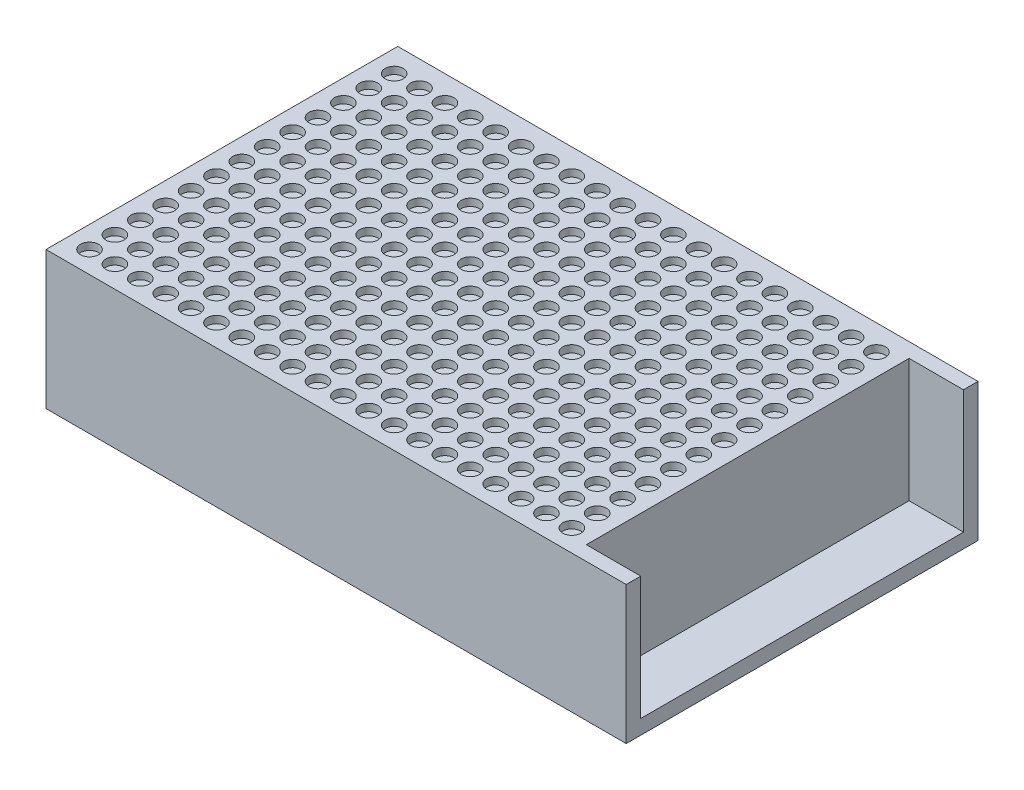
from build123d import *

# Parameters (mm, degrees)
SKETCH_1_W          = 160
SKETCH_1_H          = 97
EXTRUDE_1_DEPTH     = 38
SKETCH_2_W          = 15
SKETCH_2_H          = 89
CUT_EXTRUDE_1_DEPTH = 34
SKETCH_3_R          = 2.5
CUT_EXTRUDE_2_DEPTH = 2


with BuildPart() as part:
    # Эскиз1 → Бобышка-Вытянуть1 (new body)
    with BuildSketch(Plane(origin=(0, 0, 0), x_dir=(1, 0, 0), z_dir=(0, 1, 0))):
        with Locations((80, 48.5)):
            Rectangle(SKETCH_1_W, SKETCH_1_H)
    extrude(amount=EXTRUDE_1_DEPTH)

    # Эскиз2 → Вырез-Вытянуть1 (cut)
    with BuildSketch(Plane(origin=(0, 38, 0), x_dir=(1, 0, 0), z_dir=(0, 1, 0))):
        with Locations((152.5, 48.5)):
            Rectangle(SKETCH_2_W, SKETCH_2_H)
    extrude(amount=-CUT_EXTRUDE_1_DEPTH, mode=Mode.SUBTRACT)

    # Эскиз3 → Вырез-Вытянуть2 (cut)
    with BuildSketch(Plane(origin=(0, 38, 0), x_dir=(1, 0, 0), z_dir=(0, 1, 0))):
        with Locations((6, 6)):
            Circle(SKETCH_3_R)
        with Locations((13, 6)):
            Circle(SKETCH_3_R)
        with Locations((20, 6)):
            Circle(SKETCH_3_R)
        with Locations((27, 6)):
            Circle(SKETCH_3_R)
        with Locations((34, 6)):
            Circle(SKETCH_3_R)
        with Locations((41, 6)):
            Circle(SKETCH_3_R)
        with Locations((48, 6)):
            Circle(SKETCH_3_R)
        with Locations((55, 6)):
            Circle(SKETCH_3_R)
        with Locations((62, 6)):
            Circle(SKETCH_3_R)
        with Locations((69, 6)):
            Circle(SKETCH_3_R)
        with Locations((76, 6)):
            Circle(SKETCH_3_R)
        with Locations((83, 6)):
            Circle(SKETCH_3_R)
        with Locations((90, 6)):
            Circle(SKETCH_3_R)
        with Locations((97, 6)):
            Circle(SKETCH_3_R)
        with Locations((104, 6)):
            Circle(SKETCH_3_R)
        with Locations((111, 6)):
            Circle(SKETCH_3_R)
        with Locations((118, 6)):
            Circle(SKETCH_3_R)
        with Locations((125, 6)):
            Circle(SKETCH_3_R)
        with Locations((132, 6)):
            Circle(SKETCH_3_R)
        with Locations((139, 6)):
            Circle(SKETCH_3_R)
        with Locations((13, 13)):
            Circle(SKETCH_3_R)
        with Locations((20, 13)):
            Circle(SKETCH_3_R)
        with Locations((27, 13)):
            Circle(SKETCH_3_R)
        with Locations((34, 13)):
            Circle(SKETCH_3_R)
        with Locations((41, 13)):
            Circle(SKETCH_3_R)
        with Locations((48, 13)):
            Circle(SKETCH_3_R)
        with Locations((55, 13)):
            Circle(SKETCH_3_R)
        with Locations((62, 13)):
            Circle(SKETCH_3_R)
        with Locations((69, 13)):
            Circle(SKETCH_3_R)
        with Locations((76, 13)):
            Circle(SKETCH_3_R)
        with Locations((83, 13)):
            Circle(SKETCH_3_R)
        with Locations((90, 13)):
            Circle(SKETCH_3_R)
        with Locations((97, 13)):
            Circle(SKETCH_3_R)
        with Locations((104, 13)):
            Circle(SKETCH_3_R)
        with Locations((111, 13)):
            Circle(SKETCH_3_R)
        with Locations((118, 13)):
            Circle(SKETCH_3_R)
        with Locations((125, 13)):
            Circle(SKETCH_3_R)
        with Locations((132, 13)):
            Circle(SKETCH_3_R)
        with Locations((139, 13)):
            Circle(SKETCH_3_R)
        with Locations((13, 20)):
            Circle(SKETCH_3_R)
        with Locations((20, 20)):
            Circle(SKETCH_3_R)
        with Locations((27, 20)):
            Circle(SKETCH_3_R)
        with Locations((34, 20)):
            Circle(SKETCH_3_R)
        with Locations((41, 20)):
            Circle(SKETCH_3_R)
        with Locations((48, 20)):
            Circle(SKETCH_3_R)
        with Locations((55, 20)):
            Circle(SKETCH_3_R)
        with Locations((62, 20)):
            Circle(SKETCH_3_R)
        with Locations((69, 20)):
            Circle(SKETCH_3_R)
        with Locations((76, 20)):
            Circle(SKETCH_3_R)
        with Locations((83, 20)):
            Circle(SKETCH_3_R)
        with Locations((90, 20)):
            Circle(SKETCH_3_R)
        with Locations((97, 20)):
            Circle(SKETCH_3_R)
        with Locations((104, 20)):
            Circle(SKETCH_3_R)
        with Locations((111, 20)):
            Circle(SKETCH_3_R)
        with Locations((118, 20)):
            Circle(SKETCH_3_R)
        with Locations((125, 20)):
            Circle(SKETCH_3_R)
        with Locations((132, 20)):
            Circle(SKETCH_3_R)
        with Locations((139, 20)):
            Circle(SKETCH_3_R)
        with Locations((13, 27)):
            Circle(SKETCH_3_R)
        with Locations((20, 27)):
            Circle(SKETCH_3_R)
        with Locations((27, 27)):
            Circle(SKETCH_3_R)
        with Locations((34, 27)):
            Circle(SKETCH_3_R)
        with Locations((41, 27)):
            Circle(SKETCH_3_R)
        with Locations((48, 27)):
            Circle(SKETCH_3_R)
        with Locations((55, 27)):
            Circle(SKETCH_3_R)
        with Locations((62, 27)):
            Circle(SKETCH_3_R)
        with Locations((69, 27)):
            Circle(SKETCH_3_R)
        with Locations((76, 27)):
            Circle(SKETCH_3_R)
        with Locations((83, 27)):
            Circle(SKETCH_3_R)
        with Locations((90, 27)):
            Circle(SKETCH_3_R)
        with Locations((97, 27)):
            Circle(SKETCH_3_R)
        with Locations((104, 27)):
            Circle(SKETCH_3_R)
        with Locations((111, 27)):
            Circle(SKETCH_3_R)
        with Locations((118, 27)):
            Circle(SKETCH_3_R)
        with Locations((125, 27)):
            Circle(SKETCH_3_R)
        with Locations((132, 27)):
            Circle(SKETCH_3_R)
        with Locations((139, 27)):
            Circle(SKETCH_3_R)
        with Locations((13, 34)):
            Circle(SKETCH_3_R)
        with Locations((20, 34)):
            Circle(SKETCH_3_R)
        with Locations((27, 34)):
            Circle(SKETCH_3_R)
        with Locations((34, 34)):
            Circle(SKETCH_3_R)
        with Locations((41, 34)):
            Circle(SKETCH_3_R)
        with Locations((48, 34)):
            Circle(SKETCH_3_R)
        with Locations((55, 34)):
            Circle(SKETCH_3_R)
        with Locations((62, 34)):
            Circle(SKETCH_3_R)
        with Locations((69, 34)):
            Circle(SKETCH_3_R)
        with Locations((76, 34)):
            Circle(SKETCH_3_R)
        with Locations((83, 34)):
            Circle(SKETCH_3_R)
        with Locations((90, 34)):
            Circle(SKETCH_3_R)
        with Locations((97, 34)):
            Circle(SKETCH_3_R)
        with Locations((104, 34)):
            Circle(SKETCH_3_R)
        with Locations((111, 34)):
            Circle(SKETCH_3_R)
        with Locations((118, 34)):
            Circle(SKETCH_3_R)
        with Locations((125, 34)):
            Circle(SKETCH_3_R)
        with Locations((132, 34)):
            Circle(SKETCH_3_R)
        with Locations((139, 34)):
            Circle(SKETCH_3_R)
        with Locations((13, 41)):
            Circle(SKETCH_3_R)
        with Locations((20, 41)):
            Circle(SKETCH_3_R)
        with Locations((27, 41)):
            Circle(SKETCH_3_R)
        with Locations((34, 41)):
            Circle(SKETCH_3_R)
        with Locations((41, 41)):
            Circle(SKETCH_3_R)
        with Locations((48, 41)):
            Circle(SKETCH_3_R)
        with Locations((55, 41)):
            Circle(SKETCH_3_R)
        with Locations((62, 41)):
            Circle(SKETCH_3_R)
        with Locations((69, 41)):
            Circle(SKETCH_3_R)
        with Locations((76, 41)):
            Circle(SKETCH_3_R)
        with Locations((83, 41)):
            Circle(SKETCH_3_R)
        with Locations((90, 41)):
            Circle(SKETCH_3_R)
        with Locations((97, 41)):
            Circle(SKETCH_3_R)
        with Locations((104, 41)):
            Circle(SKETCH_3_R)
        with Locations((111, 41)):
            Circle(SKETCH_3_R)
        with Locations((118, 41)):
            Circle(SKETCH_3_R)
        with Locations((125, 41)):
            Circle(SKETCH_3_R)
        with Locations((132, 41)):
            Circle(SKETCH_3_R)
        with Locations((139, 41)):
            Circle(SKETCH_3_R)
        with Locations((13, 48)):
            Circle(SKETCH_3_R)
        with Locations((20, 48)):
            Circle(SKETCH_3_R)
        with Locations((27, 48)):
            Circle(SKETCH_3_R)
        with Locations((34, 48)):
            Circle(SKETCH_3_R)
        with Locations((41, 48)):
            Circle(SKETCH_3_R)
        with Locations((48, 48)):
            Circle(SKETCH_3_R)
        with Locations((55, 48)):
            Circle(SKETCH_3_R)
        with Locations((62, 48)):
            Circle(SKETCH_3_R)
        with Locations((69, 48)):
            Circle(SKETCH_3_R)
        with Locations((76, 48)):
            Circle(SKETCH_3_R)
        with Locations((83, 48)):
            Circle(SKETCH_3_R)
        with Locations((90, 48)):
            Circle(SKETCH_3_R)
        with Locations((97, 48)):
            Circle(SKETCH_3_R)
        with Locations((104, 48)):
            Circle(SKETCH_3_R)
        with Locations((111, 48)):
            Circle(SKETCH_3_R)
        with Locations((118, 48)):
            Circle(SKETCH_3_R)
        with Locations((125, 48)):
            Circle(SKETCH_3_R)
        with Locations((132, 48)):
            Circle(SKETCH_3_R)
        with Locations((139, 48)):
            Circle(SKETCH_3_R)
        with Locations((13, 55)):
            Circle(SKETCH_3_R)
        with Locations((20, 55)):
            Circle(SKETCH_3_R)
        with Locations((27, 55)):
            Circle(SKETCH_3_R)
        with Locations((34, 55)):
            Circle(SKETCH_3_R)
        with Locations((41, 55)):
            Circle(SKETCH_3_R)
        with Locations((48, 55)):
            Circle(SKETCH_3_R)
        with Locations((55, 55)):
            Circle(SKETCH_3_R)
        with Locations((62, 55)):
            Circle(SKETCH_3_R)
        with Locations((69, 55)):
            Circle(SKETCH_3_R)
        with Locations((76, 55)):
            Circle(SKETCH_3_R)
        with Locations((83, 55)):
            Circle(SKETCH_3_R)
        with Locations((90, 55)):
            Circle(SKETCH_3_R)
        with Locations((97, 55)):
            Circle(SKETCH_3_R)
        with Locations((104, 55)):
            Circle(SKETCH_3_R)
        with Locations((111, 55)):
            Circle(SKETCH_3_R)
        with Locations((118, 55)):
            Circle(SKETCH_3_R)
        with Locations((125, 55)):
            Circle(SKETCH_3_R)
        with Locations((132, 55)):
            Circle(SKETCH_3_R)
        with Locations((139, 55)):
            Circle(SKETCH_3_R)
        with Locations((13, 62)):
            Circle(SKETCH_3_R)
        with Locations((20, 62)):
            Circle(SKETCH_3_R)
        with Locations((27, 62)):
            Circle(SKETCH_3_R)
        with Locations((34, 62)):
            Circle(SKETCH_3_R)
        with Locations((41, 62)):
            Circle(SKETCH_3_R)
        with Locations((48, 62)):
            Circle(SKETCH_3_R)
        with Locations((55, 62)):
            Circle(SKETCH_3_R)
        with Locations((62, 62)):
            Circle(SKETCH_3_R)
        with Locations((69, 62)):
            Circle(SKETCH_3_R)
        with Locations((76, 62)):
            Circle(SKETCH_3_R)
        with Locations((83, 62)):
            Circle(SKETCH_3_R)
        with Locations((90, 62)):
            Circle(SKETCH_3_R)
        with Locations((97, 62)):
            Circle(SKETCH_3_R)
        with Locations((104, 62)):
            Circle(SKETCH_3_R)
        with Locations((111, 62)):
            Circle(SKETCH_3_R)
        with Locations((118, 62)):
            Circle(SKETCH_3_R)
        with Locations((125, 62)):
            Circle(SKETCH_3_R)
        with Locations((132, 62)):
            Circle(SKETCH_3_R)
        with Locations((139, 62)):
            Circle(SKETCH_3_R)
        with Locations((13, 69)):
            Circle(SKETCH_3_R)
        with Locations((20, 69)):
            Circle(SKETCH_3_R)
        with Locations((27, 69)):
            Circle(SKETCH_3_R)
        with Locations((34, 69)):
            Circle(SKETCH_3_R)
        with Locations((41, 69)):
            Circle(SKETCH_3_R)
        with Locations((48, 69)):
            Circle(SKETCH_3_R)
        with Locations((55, 69)):
            Circle(SKETCH_3_R)
        with Locations((62, 69)):
            Circle(SKETCH_3_R)
        with Locations((69, 69)):
            Circle(SKETCH_3_R)
        with Locations((76, 69)):
            Circle(SKETCH_3_R)
        with Locations((83, 69)):
            Circle(SKETCH_3_R)
        with Locations((90, 69)):
            Circle(SKETCH_3_R)
        with Locations((97, 69)):
            Circle(SKETCH_3_R)
        with Locations((104, 69)):
            Circle(SKETCH_3_R)
        with Locations((111, 69)):
            Circle(SKETCH_3_R)
        with Locations((118, 69)):
            Circle(SKETCH_3_R)
        with Locations((125, 69)):
            Circle(SKETCH_3_R)
        with Locations((132, 69)):
            Circle(SKETCH_3_R)
        with Locations((139, 69)):
            Circle(SKETCH_3_R)
        with Locations((13, 76)):
            Circle(SKETCH_3_R)
        with Locations((20, 76)):
            Circle(SKETCH_3_R)
        with Locations((27, 76)):
            Circle(SKETCH_3_R)
        with Locations((34, 76)):
            Circle(SKETCH_3_R)
        with Locations((41, 76)):
            Circle(SKETCH_3_R)
        with Locations((48, 76)):
            Circle(SKETCH_3_R)
        with Locations((55, 76)):
            Circle(SKETCH_3_R)
        with Locations((62, 76)):
            Circle(SKETCH_3_R)
        with Locations((69, 76)):
            Circle(SKETCH_3_R)
        with Locations((76, 76)):
            Circle(SKETCH_3_R)
        with Locations((83, 76)):
            Circle(SKETCH_3_R)
        with Locations((90, 76)):
            Circle(SKETCH_3_R)
        with Locations((97, 76)):
            Circle(SKETCH_3_R)
        with Locations((104, 76)):
            Circle(SKETCH_3_R)
        with Locations((111, 76)):
            Circle(SKETCH_3_R)
        with Locations((118, 76)):
            Circle(SKETCH_3_R)
        with Locations((125, 76)):
            Circle(SKETCH_3_R)
        with Locations((132, 76)):
            Circle(SKETCH_3_R)
        with Locations((139, 76)):
            Circle(SKETCH_3_R)
        with Locations((13, 83)):
            Circle(SKETCH_3_R)
        with Locations((20, 83)):
            Circle(SKETCH_3_R)
        with Locations((27, 83)):
            Circle(SKETCH_3_R)
        with Locations((34, 83)):
            Circle(SKETCH_3_R)
        with Locations((41, 83)):
            Circle(SKETCH_3_R)
        with Locations((48, 83)):
            Circle(SKETCH_3_R)
        with Locations((55, 83)):
            Circle(SKETCH_3_R)
        with Locations((62, 83)):
            Circle(SKETCH_3_R)
        with Locations((69, 83)):
            Circle(SKETCH_3_R)
        with Locations((76, 83)):
            Circle(SKETCH_3_R)
        with Locations((83, 83)):
            Circle(SKETCH_3_R)
        with Locations((90, 83)):
            Circle(SKETCH_3_R)
        with Locations((97, 83)):
            Circle(SKETCH_3_R)
        with Locations((104, 83)):
            Circle(SKETCH_3_R)
        with Locations((111, 83)):
            Circle(SKETCH_3_R)
        with Locations((118, 83)):
            Circle(SKETCH_3_R)
        with Locations((125, 83)):
            Circle(SKETCH_3_R)
        with Locations((132, 83)):
            Circle(SKETCH_3_R)
        with Locations((139, 83)):
            Circle(SKETCH_3_R)
        with Locations((13, 90)):
            Circle(SKETCH_3_R)
        with Locations((20, 90)):
            Circle(SKETCH_3_R)
        with Locations((27, 90)):
            Circle(SKETCH_3_R)
        with Locations((34, 90)):
            Circle(SKETCH_3_R)
        with Locations((41, 90)):
            Circle(SKETCH_3_R)
        with Locations((48, 90)):
            Circle(SKETCH_3_R)
        with Locations((55, 90)):
            Circle(SKETCH_3_R)
        with Locations((62, 90)):
            Circle(SKETCH_3_R)
        with Locations((69, 90)):
            Circle(SKETCH_3_R)
        with Locations((76, 90)):
            Circle(SKETCH_3_R)
        with Locations((83, 90)):
            Circle(SKETCH_3_R)
        with Locations((90, 90)):
            Circle(SKETCH_3_R)
        with Locations((97, 90)):
            Circle(SKETCH_3_R)
        with Locations((104, 90)):
            Circle(SKETCH_3_R)
        with Locations((111, 90)):
            Circle(SKETCH_3_R)
        with Locations((118, 90)):
            Circle(SKETCH_3_R)
        with Locations((125, 90)):
            Circle(SKETCH_3_R)
        with Locations((132, 90)):
            Circle(SKETCH_3_R)
        with Locations((139, 90)):
            Circle(SKETCH_3_R)
        with Locations((6, 13)):
            Circle(SKETCH_3_R)
        with Locations((6, 20)):
            Circle(SKETCH_3_R)
        with Locations((6, 27)):
            Circle(SKETCH_3_R)
        with Locations((6, 34)):
            Circle(SKETCH_3_R)
        with Locations((6, 41)):
            Circle(SKETCH_3_R)
        with Locations((6, 48)):
            Circle(SKETCH_3_R)
        with Locations((6, 55)):
            Circle(SKETCH_3_R)
        with Locations((6, 62)):
            Circle(SKETCH_3_R)
        with Locations((6, 69)):
            Circle(SKETCH_3_R)
        with Locations((6, 76)):
            Circle(SKETCH_3_R)
        with Locations((6, 83)):
            Circle(SKETCH_3_R)
        with Locations((6, 90)):
            Circle(SKETCH_3_R)
    extrude(amount=-CUT_EXTRUDE_2_DEPTH, mode=Mode.SUBTRACT)


solid = part.part
